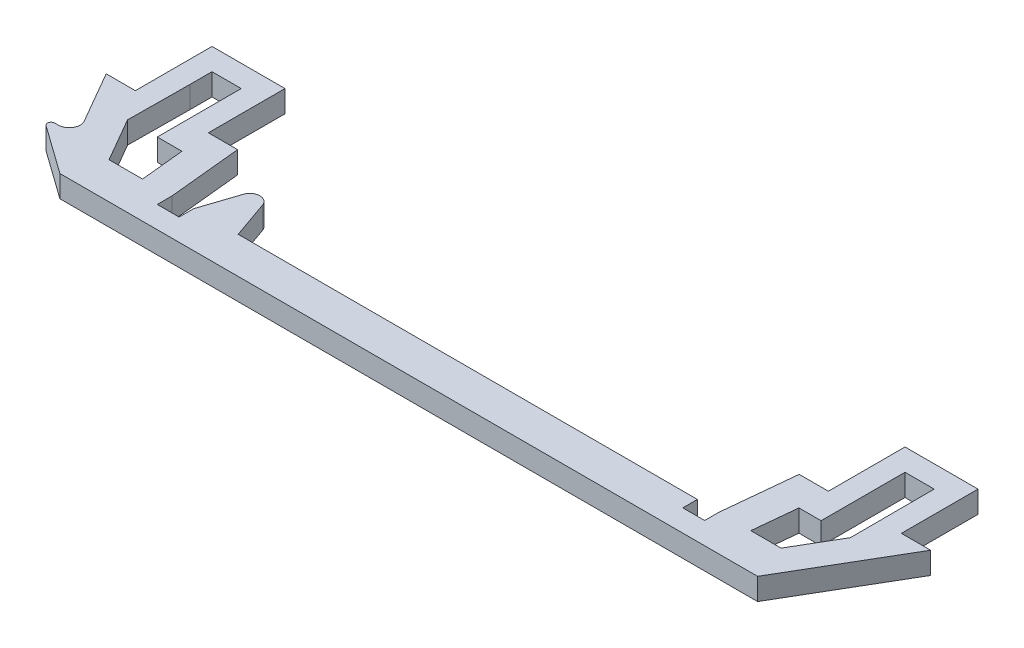
from build123d import *

# Parameters (mm, degrees)
BOSS_EXTRUDE1_DEPTH = 3


with BuildPart() as part:
    # Sketch1 → Boss-Extrude1 (new body)
    with BuildSketch(Plane(origin=(0, 0, 0), x_dir=(1, 0, 0), z_dir=(0, 1, 0))):
        with BuildLine():
            Line((-62.418566214, -48.6586621), (-58.418566214, -48.6586621))
            Line((-58.418566214, -48.6586621), (-58.418566214, -38.1586621))
            Line((-58.418566214, -38.1586621), (-48.418566214, -38.1586621))
            Line((-48.418566214, -38.1586621), (-48.418566214, -48.6586621))
            Line((-48.418566214, -48.6586621), (-44.418566214, -48.6586621))
            Line((-44.418566214, -48.6586621), (-43.418817081, -58.656153425))
            Line((-43.418817081, -58.656153425), (-43.418817081, -60.6586621))
            Line((-43.418817081, -60.6586621), (-40.418817081, -60.6586621))
            Line((-40.418817081, -60.6586621), (-40.418817081, -58.6586621))
            Line((-40.418817081, -58.6586621), (-38.722684913, -53.544656797))
            ThreePointArc((-38.722684913, -53.544656797), (-37.43326006, -52.606013311), (-36.129099744, -53.524073178))
            Line((-36.129099744, -53.524073178), (-34.335191263, -58.6586621))
            Line((-34.335191263, -58.6586621), (28.581433786, -58.6586621))
            Line((28.581433786, -58.6586621), (28.581433786, -60.6586621))
            Line((28.581433786, -60.6586621), (31.581433786, -60.6586621))
            Line((31.581433786, -60.6586621), (31.581433786, -58.708800497))
            Line((31.581433786, -58.708800497), (32.581433786, -48.711334262))
            Line((32.581433786, -48.711334262), (36.581433786, -48.711334262))
            Line((36.581433786, -48.711334262), (36.581433786, -38.211334262))
            Line((36.581433786, -38.211334262), (46.581433786, -38.211334262))
            Line((46.581433786, -38.211334262), (46.581433786, -48.711334262))
            Line((46.581433786, -48.711334262), (50.581433786, -48.711334262))
            Line((50.581433786, -48.711334262), (41.830582941, -63.6586621))
            Line((41.830582941, -63.6586621), (-53.758312176, -63.6586621))
            Line((-53.758312176, -63.6586621), (-60.382083638, -58.930990881))
            ThreePointArc((-60.382083638, -58.930990881), (-60.567785948, -58.371516574), (-60.091610782, -58.024019727))
            Line((-60.091610782, -58.024019727), (-59.609550678, -58.024019727))
            ThreePointArc((-59.609550678, -58.024019727), (-58.310512573, -57.274019727), (-58.310512573, -55.774019727))
            Line((-58.310512573, -55.774019727), (-62.418566214, -48.6586621))
        make_face()
        Polygon((36.547763078, -52.711334262), (39.581433786, -52.711334262), (39.581433786, -44.211334262), (39.581433786, -41.211334262), (43.581433786, -41.211334262), (43.581433786, -44.211334262), (43.604572315, -52.711334262), (40.093380681, -58.708800497), (35.947864455, -58.708800497), align=None, mode=Mode.SUBTRACT)
        Polygon((-55.418566214, -41.1586621), (-51.418566214, -41.1586621), (-51.418566214, -44.1586621), (-51.418566214, -52.6586621), (-48.038516462, -52.6586621), (-47.438516462, -58.6586621), (-52.026261368, -58.6586621), (-55.490362984, -52.6586621), (-55.418566214, -44.1586621), align=None, mode=Mode.SUBTRACT)
    extrude(amount=BOSS_EXTRUDE1_DEPTH)


solid = part.part
